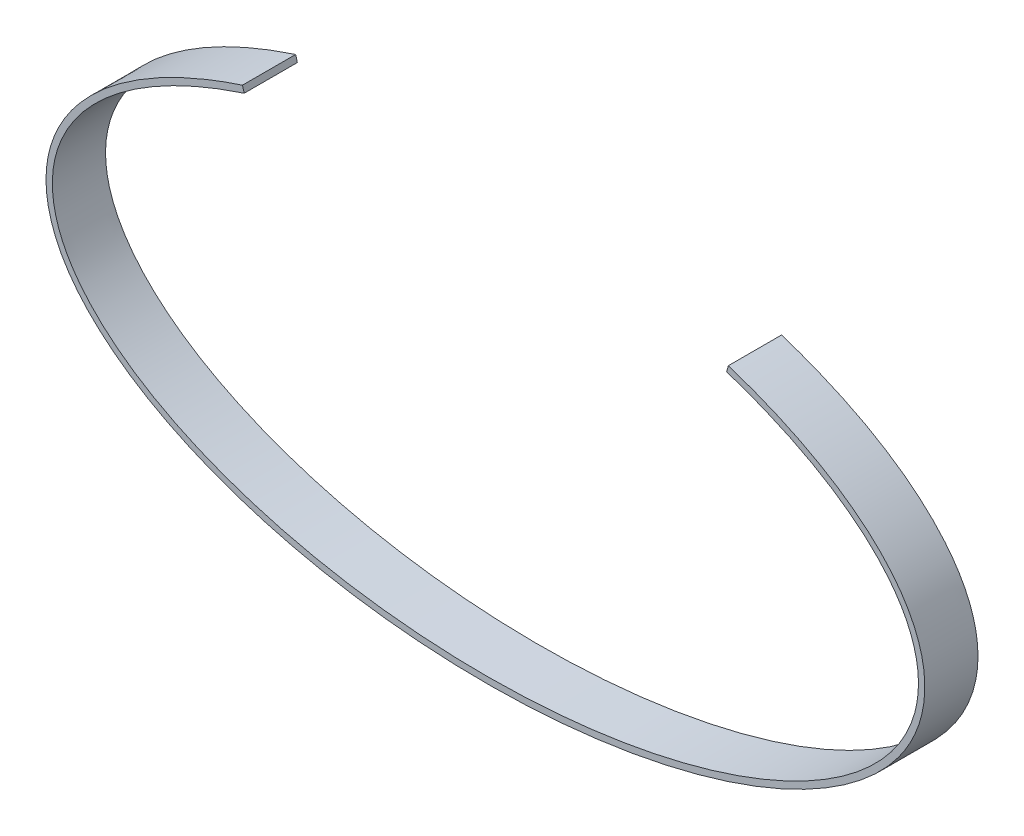
from build123d import *

# Parameters (mm, degrees)
BOSS_EXTRUDE1_DEPTH = 5


with BuildPart() as part:
    # Sketch1 → Boss-Extrude1 (new body)
    with BuildSketch(Plane.XY):
        with BuildLine():
            Line((-22.832699807, 18.61355758), (-22.67122302, 18.035135795))
            add(Edge.make_bspline(
                [(-22.67122302, 18.035135795), (-23.124450869, 17.887555236), (-23.573381515, 17.735092918), (-24.45377741, 17.42302329), (-24.885828544, 17.263249427), (-26.159733229, 16.77216597), (-26.980578501, 16.428695542), (-29.359601762, 15.350791251), (-30.829747182, 14.570143824), (-34.818143881, 12.078016232), (-36.918233445, 10.213971439), (-39.080051866, 7.267508311), (-39.637346015, 6.260917341), (-40.414776525, 4.22586311), (-40.635369943, 3.196443949), (-40.741538429, 1.132283549), (-40.625971858, 0.097722887), (-40.055523644, -1.950526079), (-39.600854478, -2.964296418), (-37.737640799, -5.948738354), (-35.836625243, -7.860287289), (-30.868087159, -11.303259049), (-27.806439664, -12.835028115), (-20.840144455, -15.354911831), (-16.93842757, -16.343173468), (-8.690092819, -17.672345004), (-4.345426267, -18.01353933), (4.345426266, -18.01353933), (8.690092818, -17.672345004), (16.938427569, -16.343173468), (20.840144454, -15.354911831), (27.806439663, -12.835028115), (30.868087158, -11.303259049), (35.836625242, -7.860287289), (37.737640798, -5.948738354), (39.600854478, -2.964296418), (40.055523644, -1.950526079), (40.625971857, 0.097722887), (40.741538428, 1.132283549), (40.635369943, 3.196443949), (40.414776524, 4.22586311), (39.637346015, 6.260917341), (39.080051866, 7.267508311), (36.918233444, 10.213971439), (34.81814388, 12.078016232), (30.829747182, 14.570143824), (29.359601761, 15.350791251), (26.980578501, 16.428695542), (26.159733228, 16.77216597), (24.885828544, 17.263249427), (24.453777409, 17.42302329), (23.573381515, 17.735092918), (23.124450869, 17.887555236), (22.671223019, 18.035135795)],
                knots=[0, 0, 0, 0, 0.0078125, 0.0078125, 0.015625, 0.015625, 0.03125, 0.03125, 0.0625, 0.0625, 0.125, 0.125, 0.15625, 0.15625, 0.1875, 0.1875, 0.21875, 0.21875, 0.25, 0.25, 0.3125, 0.3125, 0.375, 0.375, 0.4375, 0.4375, 0.5, 0.5, 0.5625, 0.5625, 0.625, 0.625, 0.6875, 0.6875, 0.75, 0.75, 0.78125, 0.78125, 0.8125, 0.8125, 0.84375, 0.84375, 0.875, 0.875, 0.9375, 0.9375, 0.96875, 0.96875, 0.984375, 0.984375, 0.9921875, 0.9921875, 1, 1, 1, 1], degree=3))
            Line((22.671223019, 18.035135795), (22.832699806, 18.61355758))
            add(Edge.make_bspline(
                [(-22.832699807, 18.61355758), (-23.291494961, 18.464424682), (-23.745078292, 18.310605996), (-24.63494783, 17.995609695), (-25.072037581, 17.834199925), (-26.36193091, 17.33766918), (-27.194704147, 16.989819959), (-29.609552705, 15.897349551), (-31.104341394, 15.104873234), (-35.172152256, 12.566706465), (-37.334324708, 10.657195977), (-39.585504015, 7.594801894), (-40.171243399, 6.541304575), (-40.994502266, 4.39304497), (-41.23127264, 3.300973606), (-41.393570656, 0.018231293), (-40.783834645, -2.188471716), (-38.207742442, -6.350097225), (-36.23880551, -8.312144299), (-31.161803498, -11.828236656), (-28.056602717, -13.381976452), (-21.011058587, -15.931795624), (-17.071691428, -16.929320901), (-8.755178766, -18.269739288), (-4.377254853, -18.61355758), (4.377254854, -18.61355758), (8.755178766, -18.269739288), (17.071691429, -16.929320901), (21.011058587, -15.931795624), (28.056602717, -13.381976452), (31.161803498, -11.828236656), (36.23880551, -8.312144299), (38.207742442, -6.350097225), (40.783834645, -2.188471716), (41.393570656, 0.018231293), (41.23127264, 3.300973606), (40.994502265, 4.39304497), (40.171243399, 6.541304575), (39.585504015, 7.594801894), (37.334324708, 10.657195977), (35.172152256, 12.566706464), (31.104341394, 15.104873234), (29.609552704, 15.897349551), (27.194704147, 16.989819959), (26.36193091, 17.33766918), (25.072037581, 17.834199925), (24.63494783, 17.995609695), (23.745078291, 18.310605996), (23.291494961, 18.464424682), (22.832699806, 18.61355758)],
                knots=[0, 0, 0, 0, 0.0078125, 0.0078125, 0.015625, 0.015625, 0.03125, 0.03125, 0.0625, 0.0625, 0.125, 0.125, 0.15625, 0.15625, 0.1875, 0.1875, 0.25, 0.25, 0.3125, 0.3125, 0.375, 0.375, 0.4375, 0.4375, 0.5, 0.5, 0.5625, 0.5625, 0.625, 0.625, 0.6875, 0.6875, 0.75, 0.75, 0.8125, 0.8125, 0.84375, 0.84375, 0.875, 0.875, 0.9375, 0.9375, 0.96875, 0.96875, 0.984375, 0.984375, 0.9921875, 0.9921875, 1, 1, 1, 1], degree=3))
        make_face()
    extrude(amount=BOSS_EXTRUDE1_DEPTH)


solid = part.part
